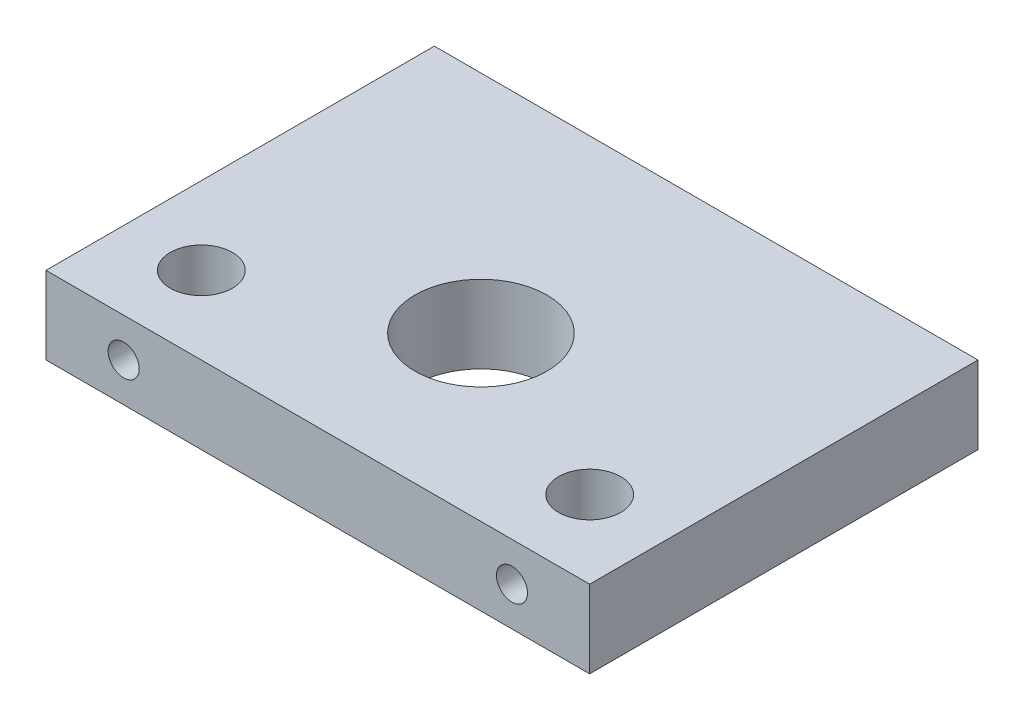
from build123d import *

# Parameters (mm, degrees)
SKETCH2_W           = 70
SKETCH2_H           = 50
BOSS_EXTRUDE1_DEPTH = 10
SKETCH3_R           = 4
CUT_EXTRUDE1_DEPTH  = 11
SKETCH4_R           = 2
CUT_EXTRUDE2_DEPTH  = 10
SKETCH5_R           = 8.5
CUT_EXTRUDE3_DEPTH  = 11.0000001


with BuildPart() as part:
    # Sketch2 → Boss-Extrude1 (new body)
    with BuildSketch(Plane(origin=(0, 0, 0), x_dir=(1, 0, 0), z_dir=(0, 1, 0))):
        Rectangle(SKETCH2_W, SKETCH2_H)
    extrude(amount=BOSS_EXTRUDE1_DEPTH)

    # Sketch3 → Cut-Extrude1 (cut, through all)
    with BuildSketch(Plane.XZ):
        with Locations((-25, 15)):
            Circle(SKETCH3_R)
        with Locations((25, 15)):
            Circle(SKETCH3_R)
    extrude(amount=-CUT_EXTRUDE1_DEPTH, mode=Mode.SUBTRACT)

    # Sketch4 → Cut-Extrude2 (cut)
    with BuildSketch(Plane.XY.offset(25)):
        with Locations((25, 5)):
            Circle(SKETCH4_R)
        with Locations((-25, 5)):
            Circle(SKETCH4_R)
    extrude(amount=-CUT_EXTRUDE2_DEPTH, mode=Mode.SUBTRACT)

    # Sketch5 → Cut-Extrude3 (cut, through all)
    with BuildSketch(Plane.XZ):
        with Locations((0, 4)):
            Circle(SKETCH5_R)
    extrude(amount=-CUT_EXTRUDE3_DEPTH, mode=Mode.SUBTRACT)


solid = part.part
